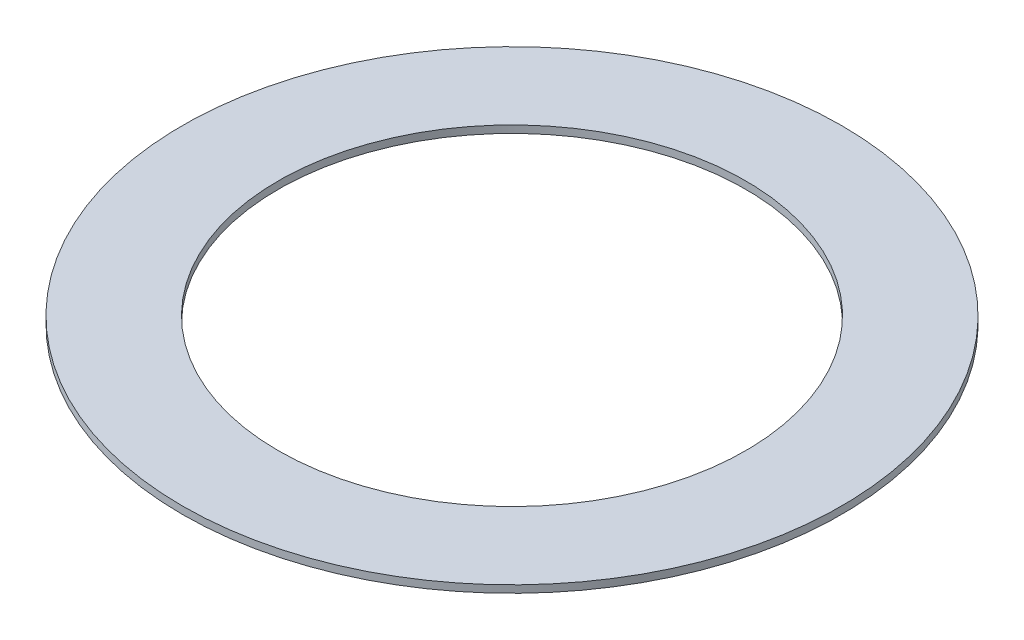
from build123d import *

# Parameters (mm, degrees)
SKETCH1_R           = 107.442
SKETCH1_R_2         = 76.2
BOSS_EXTRUDE1_DEPTH = 2.4


with BuildPart() as part:
    # Sketch1 → Boss-Extrude1 (new body)
    with BuildSketch(Plane(origin=(0, 0, 0), x_dir=(1, 0, 0), z_dir=(0, 1, 0))):
        Circle(SKETCH1_R)
        Circle(SKETCH1_R_2, mode=Mode.SUBTRACT)
    extrude(amount=BOSS_EXTRUDE1_DEPTH)


solid = part.part
